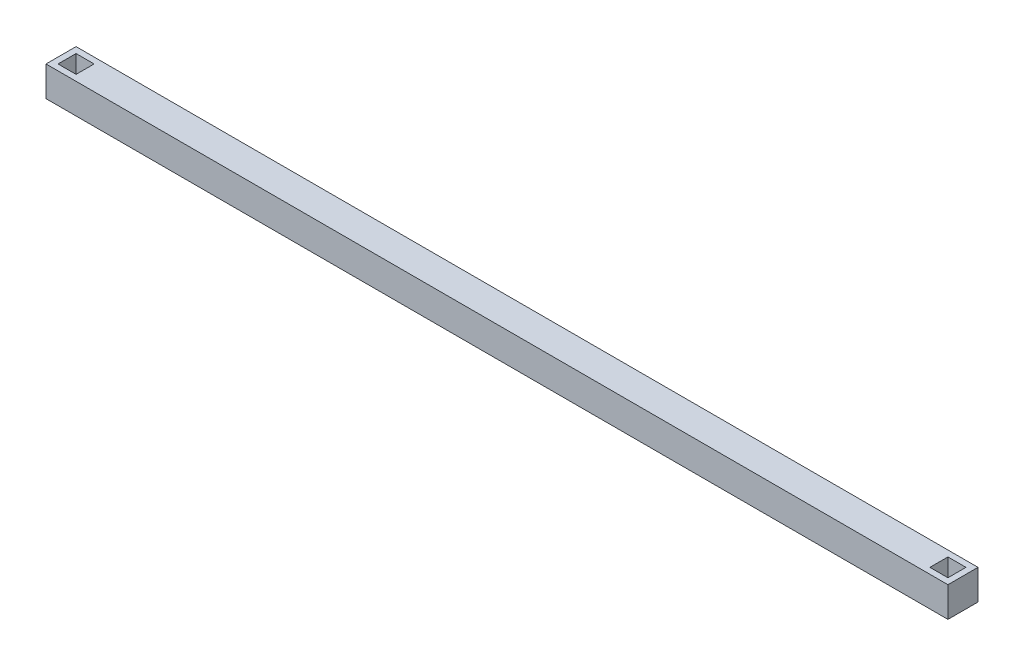
from build123d import *

# Parameters (mm, degrees)
SKETCH_1_W          = 1500
SKETCH_1_H          = 50
EXTRUDE_6_DEPTH     = 50
SKETCH_6_W          = 30
SKETCH_6_H          = 30
CUT_EXTRUDE_2_DEPTH = 30


with BuildPart() as part:
    # Эскиз1 → Бобышка-Вытянуть6 (new body)
    with BuildSketch(Plane.XY):
        Rectangle(SKETCH_1_W, SKETCH_1_H)
    extrude(amount=EXTRUDE_6_DEPTH)

    # Эскиз6 → Вырез-Вытянуть2 (cut)
    with BuildSketch(Plane(origin=(0, 25, 0), x_dir=(1, 0, 0), z_dir=(0, 1, 0))):
        with Locations((725, -25)):
            Rectangle(SKETCH_6_W, SKETCH_6_H)
        with Locations((-725, -25)):
            Rectangle(SKETCH_6_W, SKETCH_6_H)
    extrude(amount=-CUT_EXTRUDE_2_DEPTH, mode=Mode.SUBTRACT)


solid = part.part
